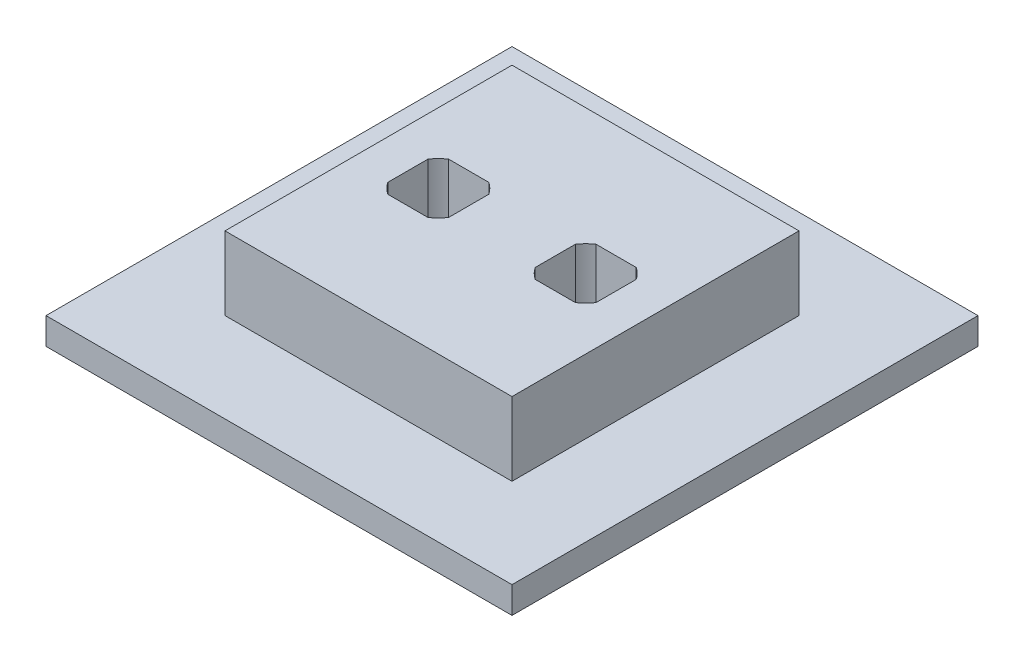
from build123d import *

# Parameters (mm, degrees)
SKETCH1_W               = 69.85
SKETCH1_H               = 69.85
BOSS_EXTRUDE1_DEPTH     = 4
SKETCH2_W               = 43.02
SKETCH2_H               = 43.02
SKETCH2_R               = 5.461
BOSS_EXTRUDE2_DEPTH     = 11
SKETCH3_R               = 5.461
CUT_EXTRUDE1_DEPTH      = 1
CUT_EXTRUDE1_DEPTH_BACK = 16
SKETCH4_W               = 43.02
SKETCH4_H               = 43.02
SKETCH4_W_2             = 9.122
SKETCH4_H_2             = 9.122
BOSS_EXTRUDE3_DEPTH     = 15


with BuildPart() as part:
    # Sketch1 → Boss-Extrude1 (new body)
    with BuildSketch(Plane(origin=(0, 0, 0), x_dir=(1, 0, 0), z_dir=(0, 1, 0))):
        with Locations((34.925, 34.925)):
            Rectangle(SKETCH1_W, SKETCH1_H)
    extrude(amount=BOSS_EXTRUDE1_DEPTH)

    # Sketch2 → Boss-Extrude2 (add)
    with BuildSketch(Plane(origin=(0, 4, 0), x_dir=(1, 0, 0), z_dir=(0, 1, 0))):
        with Locations((34.925, 34.925)):
            Rectangle(SKETCH2_W, SKETCH2_H)
        with Locations((23.876, 34.925)):
            Circle(SKETCH2_R, mode=Mode.SUBTRACT)
        with Locations((45.974, 34.925)):
            Circle(SKETCH2_R, mode=Mode.SUBTRACT)
    extrude(amount=BOSS_EXTRUDE2_DEPTH)

    # Sketch3 → Cut-Extrude1 (cut, two sides)
    with BuildSketch(Plane(origin=(0, 15, 0), x_dir=(1, 0, 0), z_dir=(0, 1, 0))) as cut_extrude1_sk:
        with Locations((23.876, 34.925)):
            Circle(SKETCH3_R)
        with Locations((45.974, 34.925)):
            Circle(SKETCH3_R)
    extrude(amount=CUT_EXTRUDE1_DEPTH, mode=Mode.SUBTRACT)
    extrude(cut_extrude1_sk.sketch, amount=-CUT_EXTRUDE1_DEPTH_BACK, mode=Mode.SUBTRACT)

    # Sketch4 → Boss-Extrude3 (add)
    with BuildSketch(Plane(origin=(0, 15, 0), x_dir=(1, 0, 0), z_dir=(0, 1, 0))):
        with Locations((34.925, 34.925)):
            Rectangle(SKETCH4_W, SKETCH4_H)
        with Locations((23.876, 34.925)):
            Rectangle(SKETCH4_W_2, SKETCH4_H_2, mode=Mode.SUBTRACT)
        with Locations((45.974, 34.925)):
            Rectangle(SKETCH4_W_2, SKETCH4_H_2, mode=Mode.SUBTRACT)
    extrude(amount=-BOSS_EXTRUDE3_DEPTH)


solid = part.part
